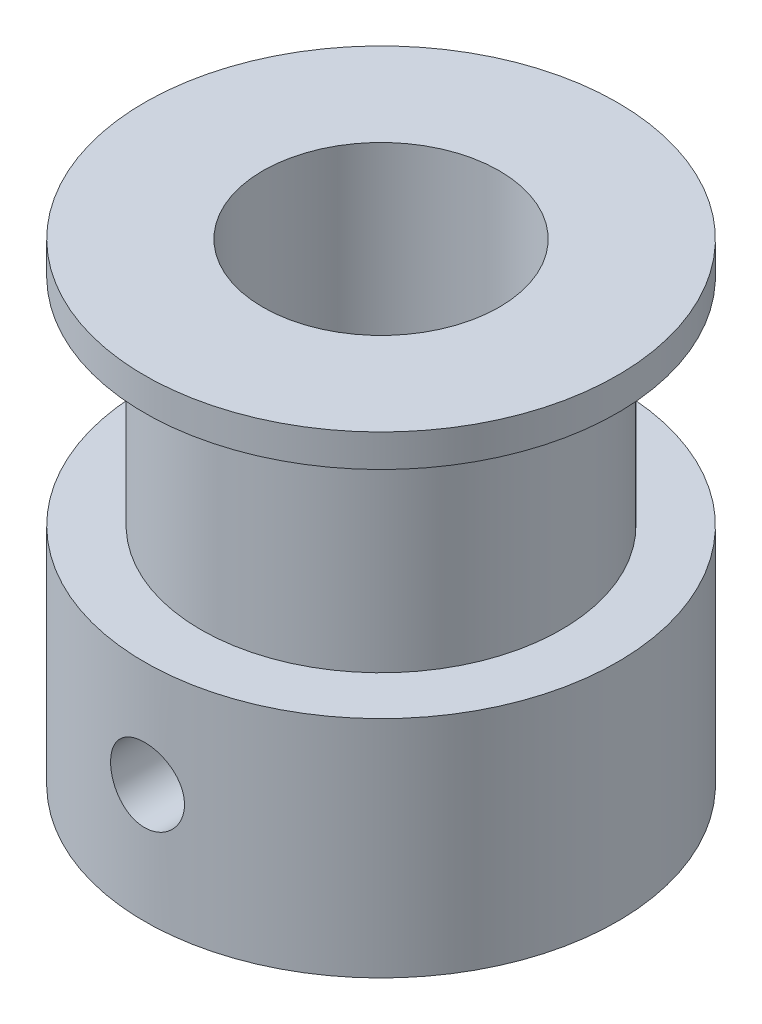
from build123d import *

# Parameters (mm, degrees)
M3_GEWINDEBOHRUNG1_REACH  = 26
M3_GEWINDEBOHRUNG1_BORE_R = 1.25
KREISMUSTER1_COUNT        = 2
KREISMUSTER1_ANGLE        = 90


with BuildPart() as part:
    # Skizze1 → Rotation1 (revolve)
    with BuildSketch(Plane.XY, mode=Mode.PRIVATE) as rotation1_sk:
        Polygon((-4, 16), (-4, 0), (-8, 0), (-8, 7.6), (-6.1, 7.6), (-6.1, 14.9), (-8, 14.9), (-8, 16), align=None)
    revolve(rotation1_sk.sketch.rotate(Axis((0, 0, 0), (0, 1, 0)), 270), axis=Axis((0, 0, 0), (0, 1, 0)))

    # M3 Gewindebohrung1 bore → M3 Gewindebohrung1 (cut, up to next)
    with BuildSketch(Plane.XY.offset(8), mode=Mode.PRIVATE) as m3_gewindebohrung1_sk1:
        with Locations((0, 4)):
            Circle(M3_GEWINDEBOHRUNG1_BORE_R)
    m3_gewindebohrung1_tool1 = extrude(m3_gewindebohrung1_sk1.sketch, amount=-M3_GEWINDEBOHRUNG1_REACH, mode=Mode.PRIVATE) & part.part
    m3_gewindebohrung1 = m3_gewindebohrung1_tool1.solids().sort_by_distance((0, 4, 8))[0]
    add(m3_gewindebohrung1, mode=Mode.SUBTRACT)

    # Kreismuster1: M3 Gewindebohrung1 ×2 about axis
    kreismuster1_axis = Axis((0, 0, 0), (0, -1, 0))
    for i in range(1, KREISMUSTER1_COUNT):
        add(m3_gewindebohrung1.rotate(kreismuster1_axis, i * KREISMUSTER1_ANGLE / (KREISMUSTER1_COUNT - 1)), mode=Mode.SUBTRACT)


solid = part.part
